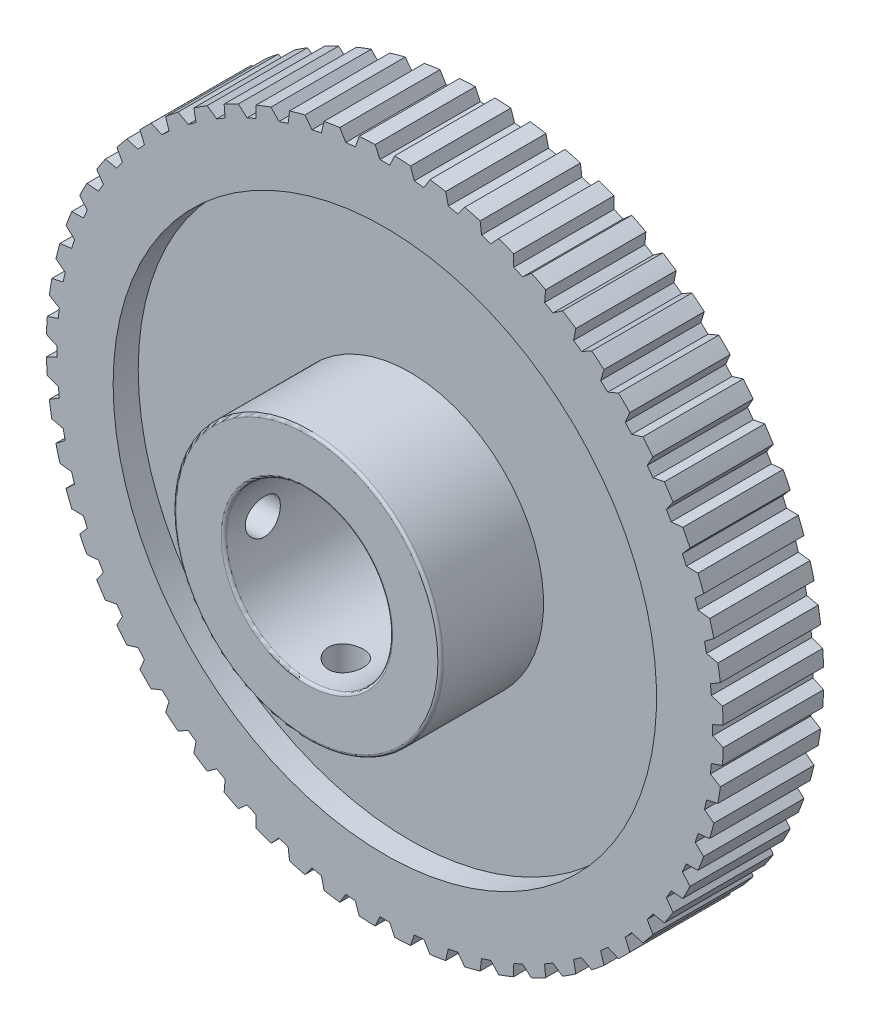
from build123d import *
from build123d.topology import SkipClean

# Parameters (mm, degrees)
CUT_EXTRUDE1_START = 1.6002
CUT_EXTRUDE1_DEPTH = 72.021703873
CIRPATTERN1_COUNT  = 60
SKETCH4_R          = 2.5
CUT_EXTRUDE2_DEPTH = 70.393595428
CIRPATTERN2_COUNT  = 2
CIRPATTERN2_ANGLE  = 90
FILLET1_R          = 0.381
SKETCH7_R          = 38.735
SKETCH7_R_2        = 19.05
CUT_EXTRUDE4_DEPTH = 14.67485
CUT_EXTRUDE5_START = -3.57505
SKETCH9_R          = 38.735
SKETCH9_R_2        = 19.05
CUT_EXTRUDE5_DEPTH = 3.57505


with BuildPart() as part:
    # Sketch2 → Revolve1 (revolve)
    with BuildSketch(Plane(origin=(0, 0, 0), x_dir=(0, 0, -1), z_dir=(1, 0, 0)), mode=Mode.PRIVATE) as revolve1_sk:
        Polygon((-12.7, 11.85), (12.7, 11.85), (12.7, 48.26), (-1.6002, 48.26), (-1.6002, 19.05), (-12.7, 19.05), align=None)
    revolve(revolve1_sk.sketch.rotate(Axis((0, 0, 12.7), (0, 0, -1)), 90), axis=Axis((0, 0, 12.7), (0, 0, -1)))

    # Sketch3 → Cut-Extrude1 (cut, through all)
    with BuildSketch(Plane.XY.offset(CUT_EXTRUDE1_START)):
        with BuildLine():
            Line((-0.690489274, 46.736), (0.690489274, 46.736))
            Line((0.690489274, 46.736), (1.391781885, 48.239926857))
            ThreePointArc((1.391781885, 48.239926857), (0, 48.26), (-1.391781885, 48.239926857))
            Line((-1.391781885, 48.239926857), (-0.690489274, 46.736))
        make_face()
    cut_extrude1 = extrude(amount=-CUT_EXTRUDE1_DEPTH, mode=Mode.SUBTRACT)

    # CirPattern1: Cut-Extrude1 ×60 about axis
    cirpattern1_axis = Axis((0, 0, 0), (0, 0, 1))
    for i in range(1, CIRPATTERN1_COUNT):
        add(cut_extrude1.rotate(cirpattern1_axis, i * 360 / CIRPATTERN1_COUNT), mode=Mode.SUBTRACT)

    # Sketch4 → Cut-Extrude2 (cut, through all)
    with BuildSketch(Plane(origin=(0, 0, 0), x_dir=(0, 0, -1), z_dir=(1, 0, 0))):
        with Locations((-7.1501, 0)):
            Circle(SKETCH4_R)
    cut_extrude2 = extrude(amount=-CUT_EXTRUDE2_DEPTH, mode=Mode.SUBTRACT)

    # CirPattern2: Cut-Extrude2 ×2 about axis
    cirpattern2_axis = Axis((0, 0, 12.7), (0, 0, 1))
    for i in range(1, CIRPATTERN2_COUNT):
        add(cut_extrude2.rotate(cirpattern2_axis, i * CIRPATTERN2_ANGLE / (CIRPATTERN2_COUNT - 1)), mode=Mode.SUBTRACT)

    # Fillet1
    fillet1_edges = [part.edges().sort_by_distance(p)[0] for p in [
        (-11.85, 0, 12.7),
        (-19.05, 0, 1.6002),
        (-19.05, 0, 12.7),
    ]]
    fillet(fillet1_edges, radius=FILLET1_R)

    # Sketch7 → Cut-Extrude4 (cut)
    with SkipClean():  # the faces are left unmerged after this step: merging them gives an invalid solid
        with BuildSketch(Plane.XY.offset(12.7)):
            with Locations(Location((0, 0, 0), (0, 0, 180))):
                Circle(SKETCH7_R)
            with Locations(Location((0, 0, 0), (0, 0, 180))):
                Circle(SKETCH7_R_2, mode=Mode.SUBTRACT)
        extrude(amount=-CUT_EXTRUDE4_DEPTH, mode=Mode.SUBTRACT)

    # Sketch9 → Cut-Extrude5 (cut)
    with SkipClean():  # the faces are left unmerged after this step: merging them gives an invalid solid
        with BuildSketch(Plane(origin=(0, 0, -12.7), x_dir=(-1, 0, 0), z_dir=(0, 0, -1)).offset(CUT_EXTRUDE5_START)):
            Circle(SKETCH9_R)
            Circle(SKETCH9_R_2, mode=Mode.SUBTRACT)
        extrude(amount=CUT_EXTRUDE5_DEPTH, mode=Mode.SUBTRACT)


solid = part.part
